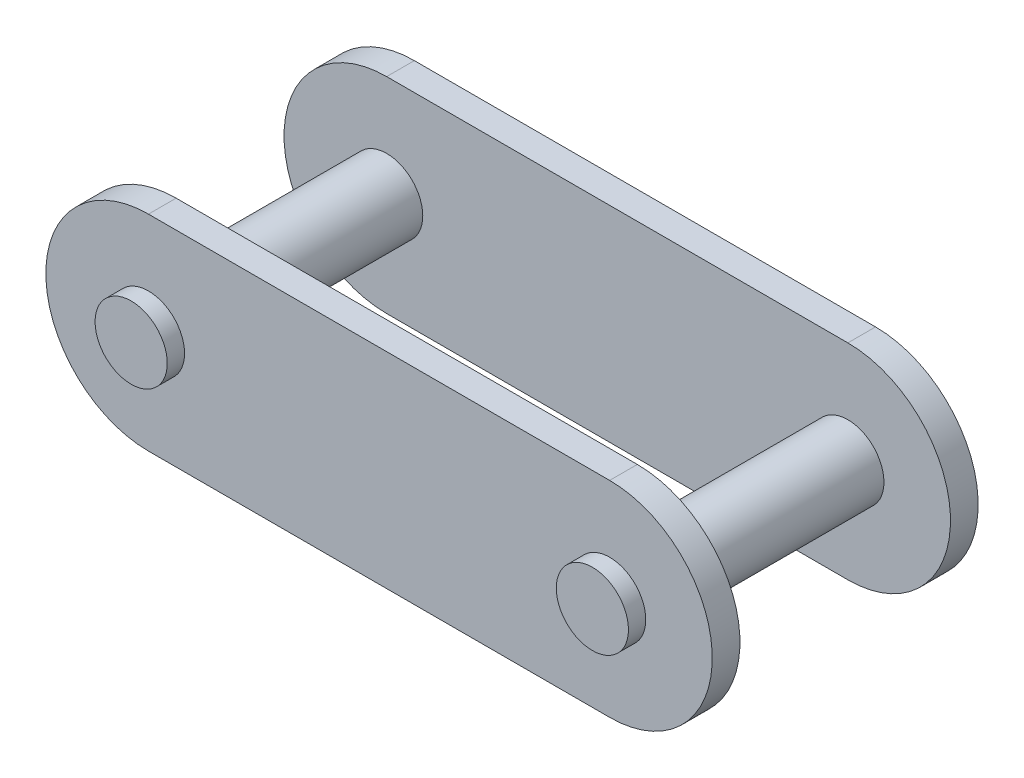
from build123d import *

# Parameters (mm, degrees)
SKETCH1_R           = 1.98755
BOSS_EXTRUDE1_DEPTH = 1.524
BOSS_EXTRUDE2_START = -2.4765
SKETCH3_R           = 1.98755
BOSS_EXTRUDE2_DEPTH = 8.27405


with BuildPart() as part:
    # Sketch1 → Boss-Extrude1 (new body)
    with BuildSketch(Plane.XY):
        with BuildLine():
            Line((-12.7, 5.6515), (12.7, 5.6515))
            ThreePointArc((12.7, 5.6515), (18.3515, 0), (12.7, -5.6515))
            Line((12.7, -5.6515), (-12.7, -5.6515))
            ThreePointArc((-12.7, -5.6515), (-18.3515, 0), (-12.7, 5.6515))
        make_face()
        with Locations((-12.7, 0)):
            Circle(SKETCH1_R, mode=Mode.SUBTRACT)
        with Locations((12.7, 0)):
            Circle(SKETCH1_R, mode=Mode.SUBTRACT)
    boss_extrude1 = extrude(amount=BOSS_EXTRUDE1_DEPTH)

    # Sketch3 → Boss-Extrude2 (add)
    with BuildSketch(Plane(origin=(0, 0, 0), x_dir=(-1, 0, 0), z_dir=(0, 0, -1)).offset(BOSS_EXTRUDE2_START)):
        with Locations((-12.7, 0)):
            Circle(SKETCH3_R)
        with Locations((12.7, 0)):
            Circle(SKETCH3_R)
    boss_extrude2 = extrude(amount=BOSS_EXTRUDE2_DEPTH)

    # Mirror4: Boss-Extrude1, Boss-Extrude2 across plane
    add(boss_extrude1.mirror(Plane.XY.offset(-5.79755)))
    add(boss_extrude2.mirror(Plane.XY.offset(-5.79755)))


solid = part.part
